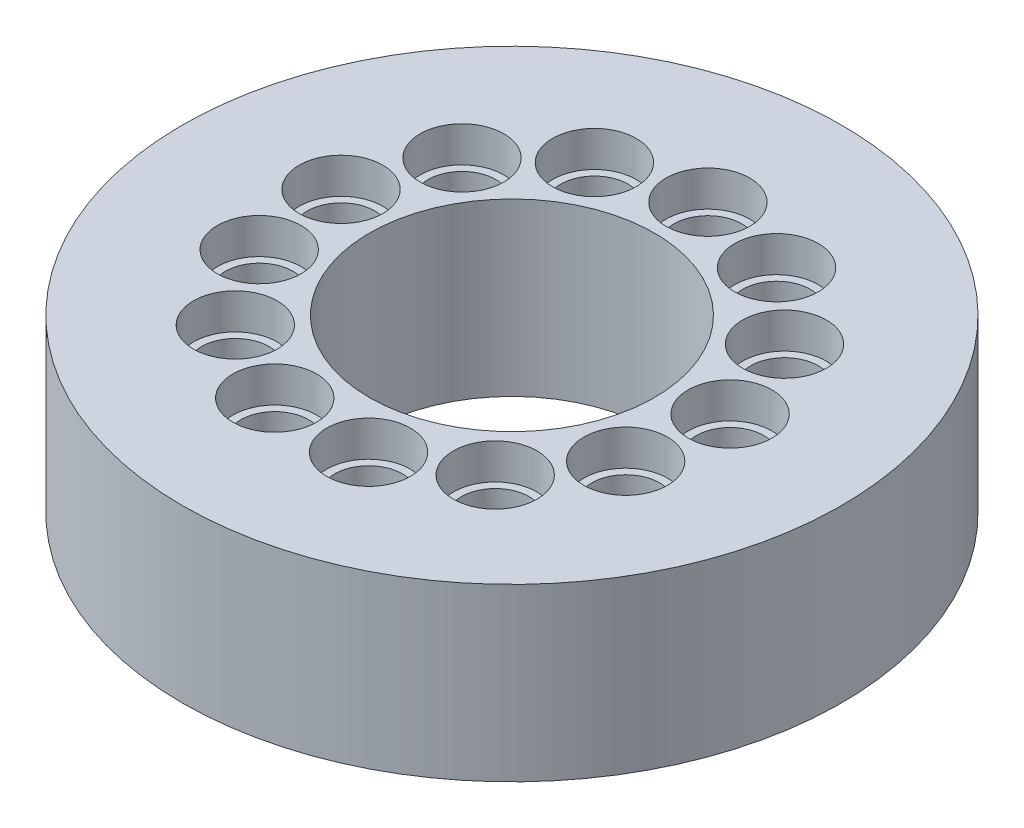
from build123d import *

# Parameters (mm, degrees)
SKETCH2_R           = 9.25
SKETCH2_R_2         = 4
BOSS_EXTRUDE1_DEPTH = 4.8
HOLE1_D             = 1.9
HOLE1_DEPTH         = 4.801
HOLE1_CBORE_D       = 2.35
HOLE1_CBORE_DEPTH   = 1
CIRPATTERN1_COUNT   = 13


with BuildPart() as part:
    # Sketch2 → Boss-Extrude1 (new body)
    with BuildSketch(Plane(origin=(0, 0, 0), x_dir=(1, 0, 0), z_dir=(0, 1, 0))):
        Circle(SKETCH2_R)
        Circle(SKETCH2_R_2, mode=Mode.SUBTRACT)
    extrude(amount=BOSS_EXTRUDE1_DEPTH)

    # Hole1
    with Locations(Plane(origin=(0, 4.8, 0), x_dir=(1, 0, 0), z_dir=(0, 1, 0))):
        with Locations((0, 5.5)):
            hole1 = CounterBoreHole(HOLE1_D / 2, HOLE1_CBORE_D / 2, HOLE1_CBORE_DEPTH, depth=HOLE1_DEPTH)

    # CirPattern1: Hole1 ×13 about axis
    cirpattern1_axis = Axis((0, 0, 0), (0, 1, 0))
    for i in range(1, CIRPATTERN1_COUNT):
        add(hole1.rotate(cirpattern1_axis, i * 360 / CIRPATTERN1_COUNT), mode=Mode.SUBTRACT)


solid = part.part
